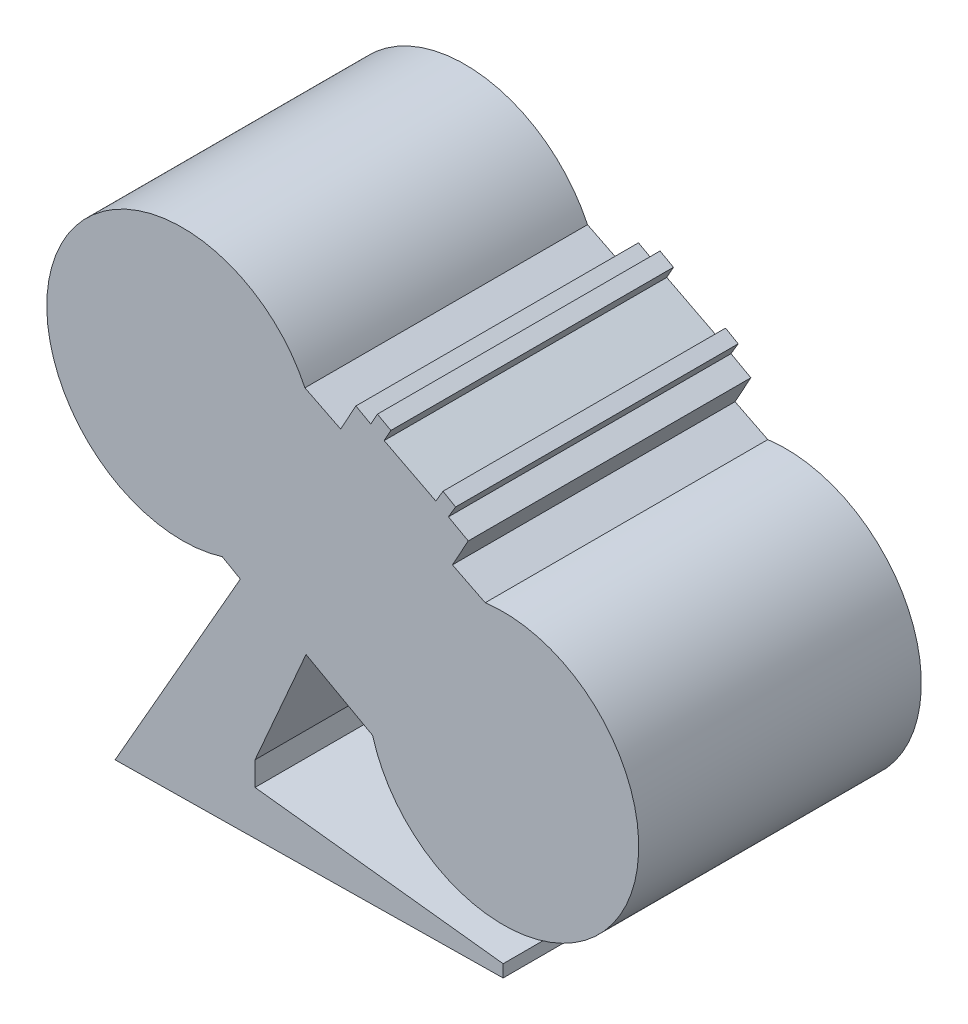
from build123d import *

# Parameters (mm, degrees)
SKETCH_1_R      = 99.790649717
SKETCH_1_R_2    = 99.803620069
EXTRUDE_1_DEPTH = 208


with BuildPart() as part:
    # 草图1 → 凸台-拉伸1 (new body)
    with BuildSketch(Plane.XY):
        with Locations((100.652828051, 264.261906095)):
            Circle(SKETCH_1_R)
        with BuildLine():
            Line((51.162061057, 0), (336.729475208, 3.724305137))
            Line((336.729475208, 3.724305137), (336.729475208, 12.826055388))
            Line((336.729475208, 12.826055388), (154.125610781, 33.873852846))
            Line((154.125610781, 33.873852846), (154.125610781, 51.508493959))
            Line((154.125610781, 51.508493959), (191.67033057, 137.40626196))
            Line((191.67033057, 137.40626196), (240.662425477, 110.352897381))
            ThreePointArc((240.662425477, 110.352897381), (253.352736169, 192.261361688), (323.548842254, 236.335698903))
            Line((323.548842254, 236.335698903), (299.418472532, 248.397124418))
            Line((299.418472532, 248.397124418), (311.058094029, 269.483395245))
            Line((311.058094029, 269.483395245), (296.467383181, 277.537467633))
            Line((296.467383181, 277.537467633), (301.706884634, 286.436303433))
            Line((301.706884634, 286.436303433), (292.477329355, 291.87052757))
            Line((292.477329355, 291.87052757), (287.237827902, 282.971691769))
            Line((287.237827902, 282.971691769), (249.158038274, 302.482086968))
            Line((249.158038274, 302.482086968), (254.098559787, 311.432307098))
            Line((254.098559787, 311.432307098), (244.217516762, 316.886642848))
            Line((244.217516762, 316.886642848), (239.358147451, 308.083437573))
            Line((239.358147451, 308.083437573), (228.350833321, 314.159474973))
            Line((228.350833321, 314.159474973), (217.125127284, 293.823050994))
            Line((217.125127284, 293.823050994), (190.848647814, 306.957197033))
            ThreePointArc((190.848647814, 306.957197033), (198.015226406, 286.14196911), (200.443477768, 264.261906095))
            ThreePointArc((200.443477768, 264.261906095), (180.931523877, 204.987082034), (130.025963153, 168.892137797))
            Line((130.025963153, 168.892137797), (143.317282357, 161.298356371))
            Line((143.317282357, 161.298356371), (51.162061057, 0))
        make_face()
        with Locations((336.729475208, 137.40626196)):
            Circle(SKETCH_1_R_2)
    extrude(amount=EXTRUDE_1_DEPTH)


solid = part.part
